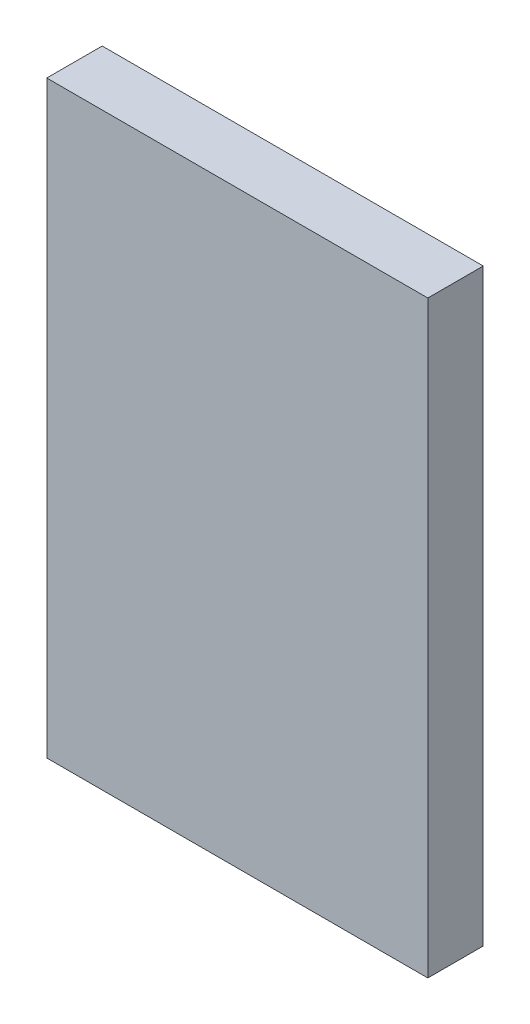
from build123d import *

# Parameters (mm, degrees)
SKETCH_1_W      = 23
SKETCH_1_H      = 54
EXTRUDE_1_DEPTH = 5
EXTRUDE_2_DEPTH = 3
SKETCH_3_W      = 55
SKETCH_3_H      = 85
EXTRUDE_3_DEPTH = 8


with BuildPart() as part:
    # 草图1 → 凸台-拉伸1 (new body)
    with BuildSketch(Plane.XY):
        Rectangle(SKETCH_1_W, SKETCH_1_H)
        Polygon((0, 6), (-5.5, 0), (0, -6), (5.5, 0), align=None, mode=Mode.SUBTRACT)
    extrude(amount=EXTRUDE_1_DEPTH)

    # 草图2 → 凸台-拉伸2 (add)
    with BuildSketch(Plane.XY.offset(5)):
        Polygon((0, -6), (5.5, 0), (0, 6), (-5.5, 0), align=None)
    extrude(amount=-EXTRUDE_2_DEPTH)

    # 草图3 → 凸台-拉伸3 (add)
    with BuildSketch(Plane.XY.offset(5)):
        Rectangle(SKETCH_3_W, SKETCH_3_H)
    extrude(amount=EXTRUDE_3_DEPTH)


solid = part.part
